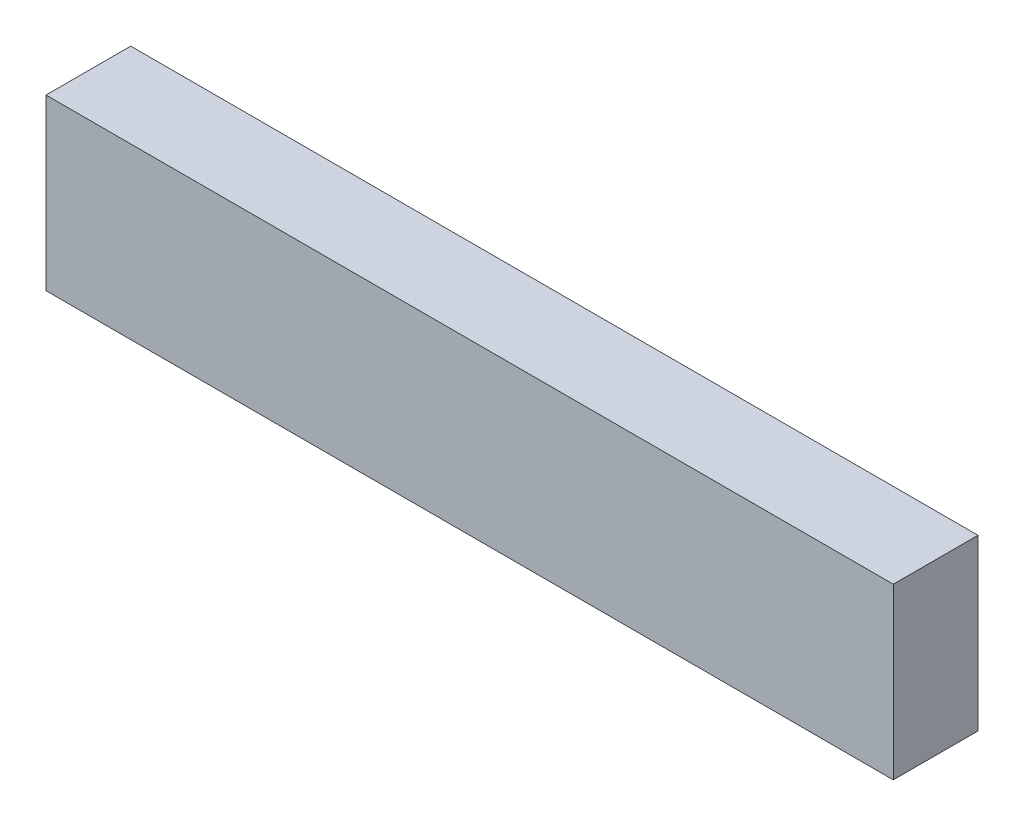
from build123d import *

# Parameters (mm, degrees)
ESQUISSE1_W        = 100
ESQUISSE1_H        = 20
BOSS_EXTRU_1_DEPTH = 10


with BuildPart() as part:
    # Esquisse1 → Boss.-Extru.1 (new body)
    with BuildSketch(Plane.XY):
        with Locations((50, 10)):
            Rectangle(ESQUISSE1_W, ESQUISSE1_H)
    extrude(amount=BOSS_EXTRU_1_DEPTH)


solid = part.part
